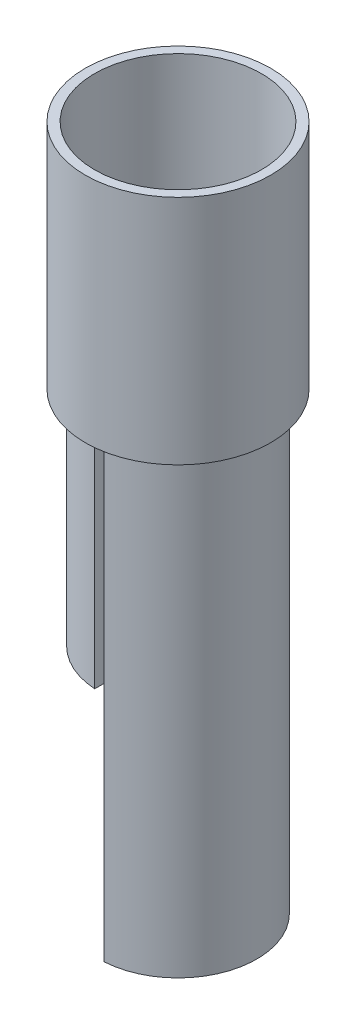
from build123d import *

# Parameters (mm, degrees)
SKETCH1_R              = 20
BOSS_EXTRUDE1_DEPTH    = 50
SHELL3_T               = -2
CUT_EXTRUDE1_DEPTH     = 50
BOSS_EXTRUDE3_DEPTH    = 50
BOSS_EXTRUDE3_2_DEPTH  = 50
SHELL6_T               = -2
SHELL7_T               = -2
PROCESSINGADJUST_DEPTH = 50


with BuildPart() as part:
    # Sketch1 → Boss-Extrude1 (new body)
    with BuildSketch(Plane(origin=(0, 0, 0), x_dir=(1, 0, 0), z_dir=(0, 1, 0))):
        with Locations(Location((0, 0, 0), (0, 0, 270))):
            Circle(SKETCH1_R)
    extrude(amount=BOSS_EXTRUDE1_DEPTH)

    # Shell3
    shell3_openings = [part.faces().sort_by_distance(p)[0] for p in [
        (0, 50, 0),
    ]]
    offset(amount=SHELL3_T, openings=shell3_openings, kind=Kind.INTERSECTION)

    # Sketch2 → Cut-Extrude1 (cut)
    with BuildSketch(Plane(origin=(0, 2, 0), x_dir=(1, 0, 0), z_dir=(0, 1, 0))):
        with BuildLine():
            ThreePointArc((17, 0), (12.369316877, 11.66190379), (1, 16.970562748))
            Line((1, 16.970562748), (1, -16.970562748))
            ThreePointArc((1, -16.970562748), (12.369316877, -11.66190379), (17, 0))
        make_face()
        with BuildLine():
            Line((-1, -16.970562748), (-1, 16.970562748))
            ThreePointArc((-1, 16.970562748), (-17, 0), (-1, -16.970562748))
        make_face()
    extrude(amount=-CUT_EXTRUDE1_DEPTH, mode=Mode.SUBTRACT)


with BuildPart() as body_2:
    # Sketch2 → Boss-Extrude3 (new body)
    with BuildSketch(Plane(origin=(0, 2, 0), x_dir=(1, 0, 0), z_dir=(0, 1, 0))):
        with BuildLine():
            ThreePointArc((17, 0), (12.369316877, 11.66190379), (1, 16.970562748))
            Line((1, 16.970562748), (1, -16.970562748))
            ThreePointArc((1, -16.970562748), (12.369316877, -11.66190379), (17, 0))
        make_face()
    extrude(amount=-BOSS_EXTRUDE3_DEPTH)

    # Shell6
    shell6_openings = [body_2.faces().sort_by_distance(p)[0] for p in [
        (7.758345486, -48, 0),
        (7.758345486, 2, 0),
    ]]
    offset(amount=SHELL6_T, openings=shell6_openings)

    # Sketch7 → processingadjust (add)
    with BuildSketch(Plane.XZ.offset(48)):
        with BuildLine():
            Line((1, 16.970562748), (1, -16.970562748))
            ThreePointArc((1, -16.970562748), (17, 0), (1, 16.970562748))
        make_face()
        with BuildLine():
            Line((3, 14.696938457), (3, -14.696938457))
            ThreePointArc((3, -14.696938457), (15, 0), (3, 14.696938457))
        make_face(mode=Mode.SUBTRACT)
    extrude(amount=PROCESSINGADJUST_DEPTH)


with BuildPart() as body_3:
    # Sketch2 → Boss-Extrude3 2 (new body)
    with BuildSketch(Plane(origin=(0, 2, 0), x_dir=(1, 0, 0), z_dir=(0, 1, 0))):
        with BuildLine():
            Line((-1, -16.970562748), (-1, 16.970562748))
            ThreePointArc((-1, 16.970562748), (-17, 0), (-1, -16.970562748))
        make_face()
    extrude(amount=-BOSS_EXTRUDE3_2_DEPTH)

    # Shell7
    shell7_openings = [body_3.faces().sort_by_distance(p)[0] for p in [
        (-7.758345486, -48, 0),
        (-7.758345486, 2, 0),
    ]]
    offset(amount=SHELL7_T, openings=shell7_openings)


solid = Compound([part.part, body_2.part, body_3.part])
